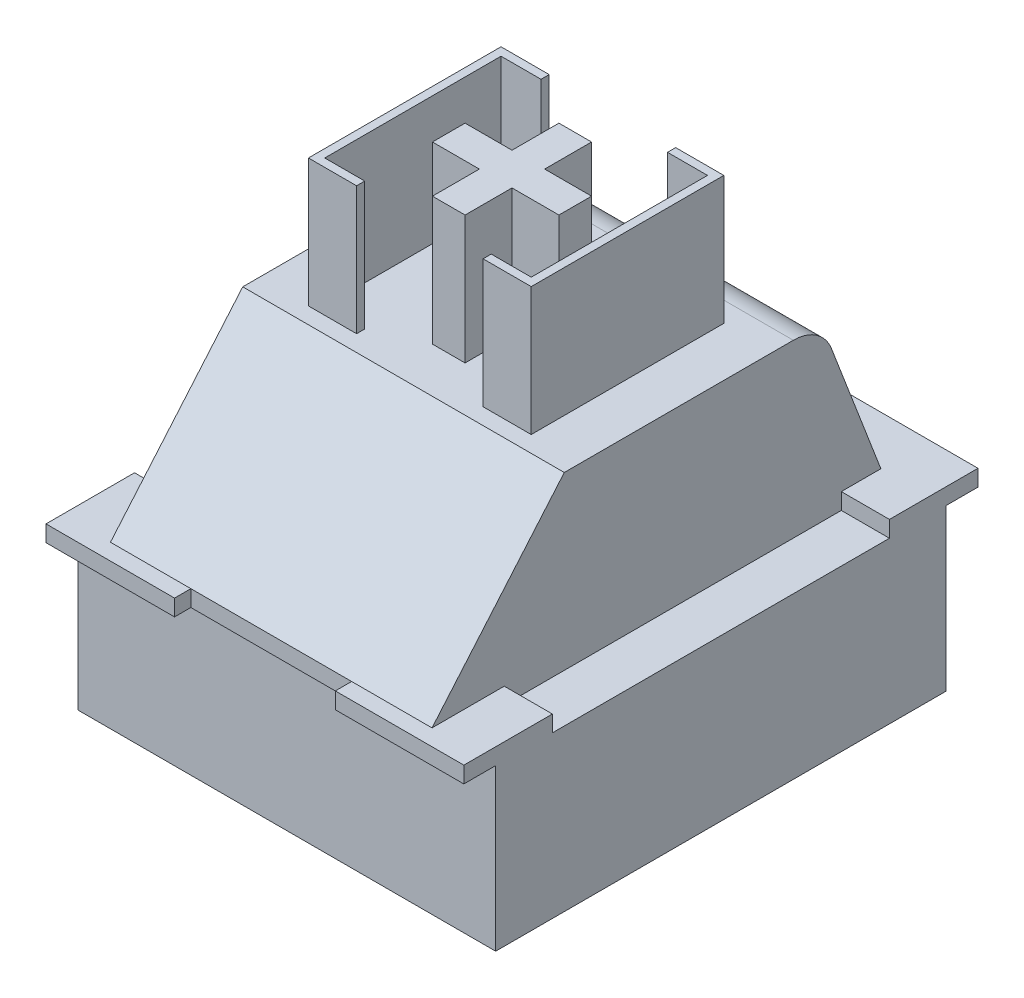
from build123d import *

# Parameters (mm, degrees)
SALIENTE_EXTRUIR1_DEPTH      = 6.5024
SALIENTE_EXTRUIR1_DEPTH_BACK = 6.5024
SALIENTE_EXTRUIR2_DEPTH      = 5.0038
SALIENTE_EXTRUIR2_DEPTH_BACK = 5.0038
CROQUIS1_4_W                 = 5.9944
CROQUIS1_4_H                 = 3.9878
SALIENTE_EXTRUIR3_DEPTH      = 3.4671
SALIENTE_EXTRUIR3_DEPTH_BACK = 3.4671
CROQUIS2_W                   = 5.0038
CROQUIS2_H                   = 0.508
CROQUIS2_H_2                 = 1.524
CROQUIS2_W_2                 = 1.4986
CROQUIS2_H_3                 = 10.4902
CORTAR_EXTRUIR1_DEPTH        = 0.508
CROQUIS3_OUTSIDE_W           = 20.026
CROQUIS3_OUTSIDE_H           = 23.024
CORTAR_EXTRUIR2_DEPTH        = 3.9878


with BuildPart() as part:
    # Croquis1 → Saliente-Extruir1 (new body, two sides)
    with BuildSketch(Plane(origin=(0, 0, 0), x_dir=(0, 0, -1), z_dir=(1, 0, 0))) as saliente_extruir1_sk:
        Polygon((-3.5052, 3.0099), (-7.493, 3.0099), (-8.001, 3.0099), (-8.001, 2.5019), (-7.0104, 2.5019), (-7.0104, -2.5019), (7.0104, -2.5019), (7.0104, 2.5019), (8.001, 2.5019), (8.001, 3.0099), (6.477, 3.0099), align=None)
    extrude(amount=SALIENTE_EXTRUIR1_DEPTH)
    extrude(saliente_extruir1_sk.sketch, amount=-SALIENTE_EXTRUIR1_DEPTH_BACK)

    # Croquis1_3 → Saliente-Extruir2 (add, two sides)
    with BuildSketch(Plane(origin=(0, 0, 0), x_dir=(0, 0, -1), z_dir=(1, 0, 0))) as saliente_extruir2_sk:
        with BuildLine():
            Line((-2.868527833, 7.8359), (-3.376527833, 7.8359))
            Line((-3.376527833, 7.8359), (-7.493, 3.0099))
            Line((-7.493, 3.0099), (-3.5052, 3.0099))
            Line((-3.5052, 3.0099), (6.477, 3.0099))
            Line((6.477, 3.0099), (4.937272491, 7.021027296))
            ThreePointArc((4.937272491, 7.021027296), (4.47096127, 7.61254026), (3.751625349, 7.8359))
            Line((3.751625349, 7.8359), (3.125872167, 7.8359))
            Line((3.125872167, 7.8359), (-2.868527833, 7.8359))
        make_face()
    extrude(amount=SALIENTE_EXTRUIR2_DEPTH)
    extrude(saliente_extruir2_sk.sketch, amount=-SALIENTE_EXTRUIR2_DEPTH_BACK)

    # Croquis1_4 → Saliente-Extruir3 (add, two sides)
    with BuildSketch(Plane(origin=(0, 0, 0), x_dir=(0, 0, -1), z_dir=(1, 0, 0))) as saliente_extruir3_sk:
        with Locations((0.128672167, 9.8298)):
            Rectangle(CROQUIS1_4_W, CROQUIS1_4_H)
    extrude(amount=SALIENTE_EXTRUIR3_DEPTH)
    extrude(saliente_extruir3_sk.sketch, amount=-SALIENTE_EXTRUIR3_DEPTH_BACK)

    # Croquis2 → Cortar-Extruir1 (cut)
    with BuildSketch(Plane(origin=(0, 3.0099, 0), x_dir=(1, 0, 0), z_dir=(0, 1, 0))):
        with Locations((0, -7.747)):
            Rectangle(CROQUIS2_W, CROQUIS2_H)
        with Locations((0, 7.239)):
            Rectangle(CROQUIS2_W, CROQUIS2_H_2)
        with Locations((-5.7531, 0)):
            Rectangle(CROQUIS2_W_2, CROQUIS2_H_3)
        with Locations((5.7531, 0)):
            Rectangle(CROQUIS2_W_2, CROQUIS2_H_3)
    extrude(amount=-CORTAR_EXTRUIR1_DEPTH, mode=Mode.SUBTRACT)

    # Croquis3 outside → Cortar-Extruir2 (cut)
    with BuildSketch(Plane(origin=(0, 11.8237, 0), x_dir=(1, 0, 0), z_dir=(0, 1, 0))):
        Rectangle(CROQUIS3_OUTSIDE_W, CROQUIS3_OUTSIDE_H)
        Polygon((-3.4671, 3.125872167), (-3.4671, -2.868527833), (-1.9685, -2.868527833), (-1.9685, -2.614527833), (-3.2131, -2.614527833), (-3.2131, 2.871872167), (-1.9685, 2.871872167), (-1.9685, 3.125872167), align=None, mode=Mode.SUBTRACT)
        Polygon((0.508, 1.9685), (-0.508, 1.9685), (-0.508, 0.508), (-1.9685, 0.508), (-1.9685, -0.508), (-0.508, -0.508), (-0.508, -1.9685), (0.508, -1.9685), (0.508, -0.508), (1.9685, -0.508), (1.9685, 0.508), (0.508, 0.508), align=None, mode=Mode.SUBTRACT)
        Polygon((3.2131, 2.871872167), (3.2131, -2.614527833), (1.9685, -2.614527833), (1.9685, -2.868527833), (3.4671, -2.868527833), (3.4671, 3.125872167), (1.9685, 3.125872167), (1.9685, 2.871872167), align=None, mode=Mode.SUBTRACT)
    extrude(amount=-CORTAR_EXTRUIR2_DEPTH, mode=Mode.SUBTRACT)


solid = part.part
